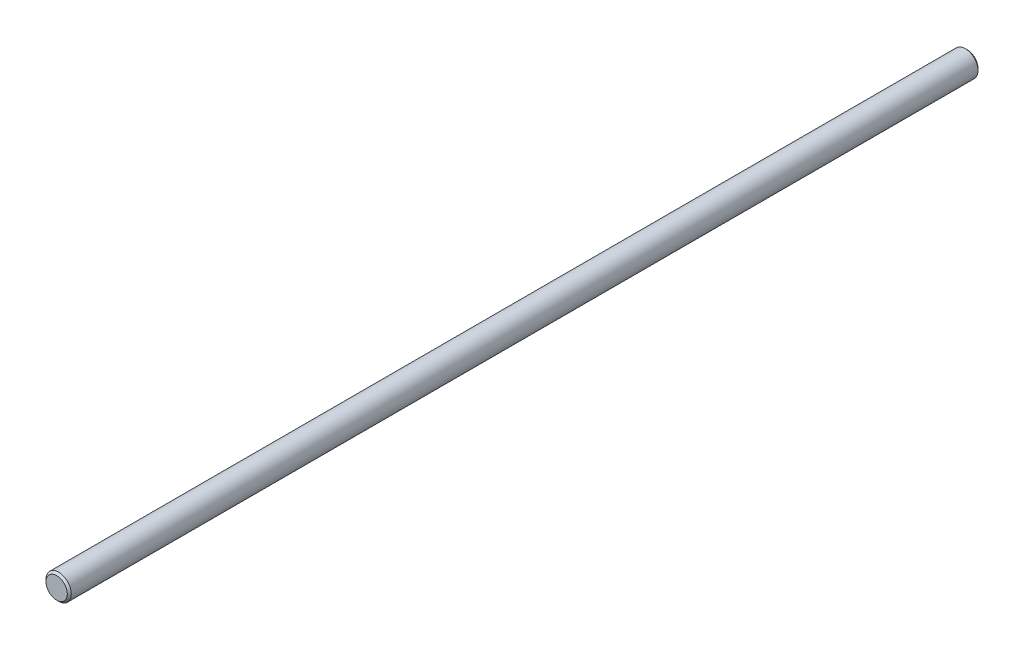
from build123d import *

# Parameters (mm, degrees)
SKETCH1_R           = 3.175
BOSS_EXTRUDE1_DEPTH = 228.6
CHAMFER1_SIZE       = 0.5


with BuildPart() as part:
    # Sketch1 → Boss-Extrude1 (new body)
    with BuildSketch(Plane.XY):
        Circle(SKETCH1_R)
    extrude(amount=BOSS_EXTRUDE1_DEPTH)

    # Chamfer1
    chamfer1_edges = [part.edges().sort_by_distance(p)[0] for p in [
        (-3.175, 0, 0),
        (-3.175, 0, 228.6),
    ]]
    chamfer(chamfer1_edges, length=CHAMFER1_SIZE)


solid = part.part
